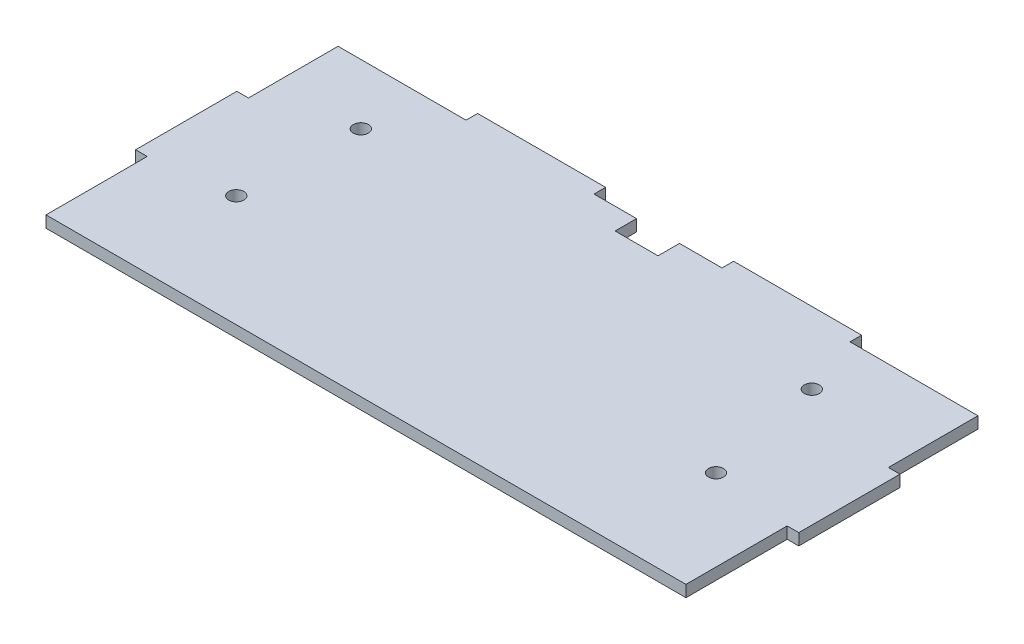
from build123d import *

# Parameters (mm, degrees)
SKETCH1_R           = 1.75
BOSS_EXTRUDE1_DEPTH = 2.7


with BuildPart() as part:
    # Sketch1 → Boss-Extrude1 (new body)
    with BuildSketch(Plane(origin=(0, 0, 0), x_dir=(1, 0, 0), z_dir=(0, 1, 0))):
        Polygon((64.5, 63), (64.5, 58), (74.5, 58), (74.5, 63), (84.4, 63), (84.4, 65.7), (114.2, 65.7), (114.2, 63), (144, 63), (144, 42.133333333), (146.7, 42.133333333), (146.7, 18.566666667), (144, 18.566666667), (144, -5), (115.82, -5), (84.94, -5), (74.5, -5), (64.5, -5), (54.06, -5), (23.18, -5), (-5, -5), (-5, 18.566666667), (-7.7, 18.566666667), (-7.7, 42.133333333), (-5, 42.133333333), (-5, 63), (24.8, 63), (24.8, 65.7), (54.6, 65.7), (54.6, 63), align=None)
        with Locations((13.3, 21)):
            Circle(SKETCH1_R, mode=Mode.SUBTRACT)
        with Locations((14.3, 49)):
            Circle(SKETCH1_R, mode=Mode.SUBTRACT)
        with Locations((119.3, 49)):
            Circle(SKETCH1_R, mode=Mode.SUBTRACT)
        with Locations((125, 21)):
            Circle(SKETCH1_R, mode=Mode.SUBTRACT)
    extrude(amount=BOSS_EXTRUDE1_DEPTH)


solid = part.part
